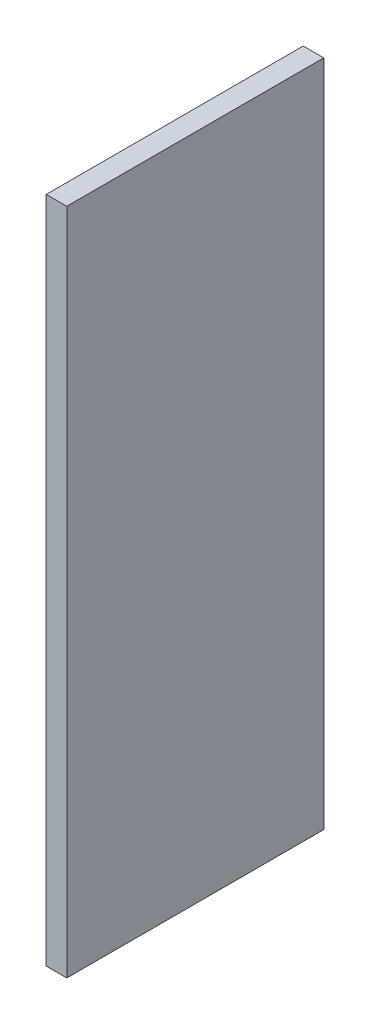
from build123d import *

# Parameters (mm, degrees)
SKETCH1_W           = 0.4
SKETCH1_H           = 13
BOSS_EXTRUDE1_DEPTH = 5


with BuildPart() as part:
    # Sketch1 → Boss-Extrude1 (new body)
    with BuildSketch(Plane.XY):
        with Locations((0.2, 6.5)):
            Rectangle(SKETCH1_W, SKETCH1_H)
    extrude(amount=BOSS_EXTRUDE1_DEPTH)


solid = part.part
